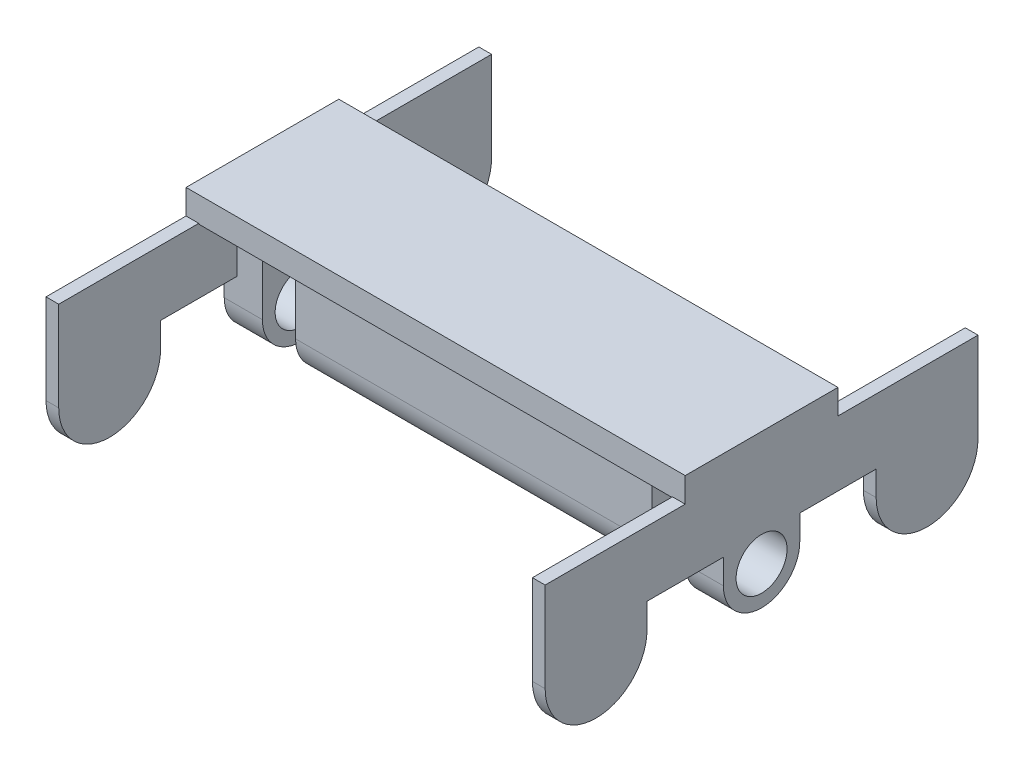
from build123d import *

# Parameters (mm, degrees)
SKETCH1_R           = 1.001
SKETCH1_W           = 6
SKETCH1_H           = 1
BOSS_EXTRUDE1_DEPTH = 18.604
CUT_EXTRUDE1_REACH  = 8
SKETCH2_W           = 1.302
SKETCH2_H           = 5.804323037
SKETCH2_H_2         = 5.909581117
CUT_EXTRUDE2_REACH  = 18.302
SKETCH3_R           = 0.75
BOSS_EXTRUDE2_DEPTH = 0.5


with BuildPart() as part:
    # Sketch1 → Boss-Extrude1 (new body)
    with BuildSketch(Plane(origin=(0, 0, 0), x_dir=(0, 0, -1), z_dir=(1, 0, 0))):
        with BuildLine():
            Line((1.5, -4), (1.5, -0.5))
            Line((1.5, -0.5), (-1.5, -0.5))
            Line((-1.5, -0.5), (-1.5, -4))
            ThreePointArc((-1.5, -4), (0, -5.5), (1.5, -4))
        make_face()
        with Locations((0, -4)):
            Circle(SKETCH1_R, mode=Mode.SUBTRACT)
        Rectangle(SKETCH1_W, SKETCH1_H)
    extrude(amount=BOSS_EXTRUDE1_DEPTH)

    # Sketch2 → Cut-Extrude1 (cut, up to next)
    with BuildSketch(Plane.XY.offset(3), mode=Mode.PRIVATE) as cut_extrude1_sk1:
        with Locations((1.651, -3.402161519)):
            Rectangle(SKETCH2_W, SKETCH2_H)
    cut_extrude1_tool1 = extrude(cut_extrude1_sk1.sketch, amount=-CUT_EXTRUDE1_REACH, mode=Mode.PRIVATE) & part.part
    add(cut_extrude1_tool1.solids().sort_by_distance((1.651, -3.402162, 3))[0], mode=Mode.SUBTRACT)
    # Sketch2 → Cut-Extrude1 (cut, up to next)
    with BuildSketch(Plane.XY.offset(3), mode=Mode.PRIVATE) as cut_extrude1_sk2:
        with Locations((16.953, -3.454790559)):
            Rectangle(SKETCH2_W, SKETCH2_H_2)
    cut_extrude1_tool2 = extrude(cut_extrude1_sk2.sketch, amount=-CUT_EXTRUDE1_REACH, mode=Mode.PRIVATE) & part.part
    add(cut_extrude1_tool2.solids().sort_by_distance((16.953, -3.454791, 3))[0], mode=Mode.SUBTRACT)

    # Sketch3 → Cut-Extrude2 (cut, up to next)
    with BuildSketch(Plane.ZY.offset(-2.302), mode=Mode.PRIVATE) as cut_extrude2_sk1:
        with Locations((0, -1.75)):
            Circle(SKETCH3_R)
    cut_extrude2_tool1 = extrude(cut_extrude2_sk1.sketch, amount=-CUT_EXTRUDE2_REACH, mode=Mode.PRIVATE) & part.part
    add(cut_extrude2_tool1.solids().sort_by_distance((2.302, -1.75, 0))[0], mode=Mode.SUBTRACT)

    # Sketch4 → Boss-Extrude2 (add)
    with BuildSketch(Plane(origin=(18.604, 0, 0), x_dir=(0, 0, -1), z_dir=(1, 0, 0))):
        with BuildLine():
            Line((-4.5, -4), (-4.5, -3.026257348))
            Line((-4.5, -3.026257348), (-1.5, -3.026257348))
            Line((-1.5, -3.026257348), (-1.5, -4))
            ThreePointArc((-1.5, -4), (0, -5.5), (1.5, -4))
            Line((1.5, -4), (1.5, -3.026257348))
            Line((1.5, -3.026257348), (4.5, -3.026257348))
            Line((4.5, -3.026257348), (4.5, -4))
            ThreePointArc((4.5, -4), (6.5, -6), (8.5, -4))
            Line((8.5, -4), (8.5, -3.026257348))
            Line((8.5, -3.026257348), (8.5, -0.472742652))
            Line((8.5, -0.472742652), (3, -0.472742652))
            Line((3, -0.472742652), (3, 0.5))
            Line((3, 0.5), (-3, 0.5))
            Line((-3, 0.5), (-3, -0.472742652))
            Line((-3, -0.472742652), (-8.5, -0.472742652))
            Line((-8.5, -0.472742652), (-8.5, -3.026257348))
            Line((-8.5, -3.026257348), (-8.5, -4))
            ThreePointArc((-8.5, -4), (-6.5, -6), (-4.5, -4))
        make_face()
        with BuildLine():
            ThreePointArc((1.001, -4), (-0.620388649, -4.785569173), (-0.232004845, -3.026257348))
            ThreePointArc((-0.232004845, -3.026257348), (0, -2.999), (0.232004845, -3.026257348))
            ThreePointArc((0.232004845, -3.026257348), (0.785569173, -3.379611351), (1.001, -4))
        make_face(mode=Mode.SUBTRACT)
    boss_extrude2 = extrude(amount=BOSS_EXTRUDE2_DEPTH)

    # Mirror2: Boss-Extrude2 across plane
    add(boss_extrude2.mirror(Plane.ZY.offset(-9.302)))


solid = part.part
